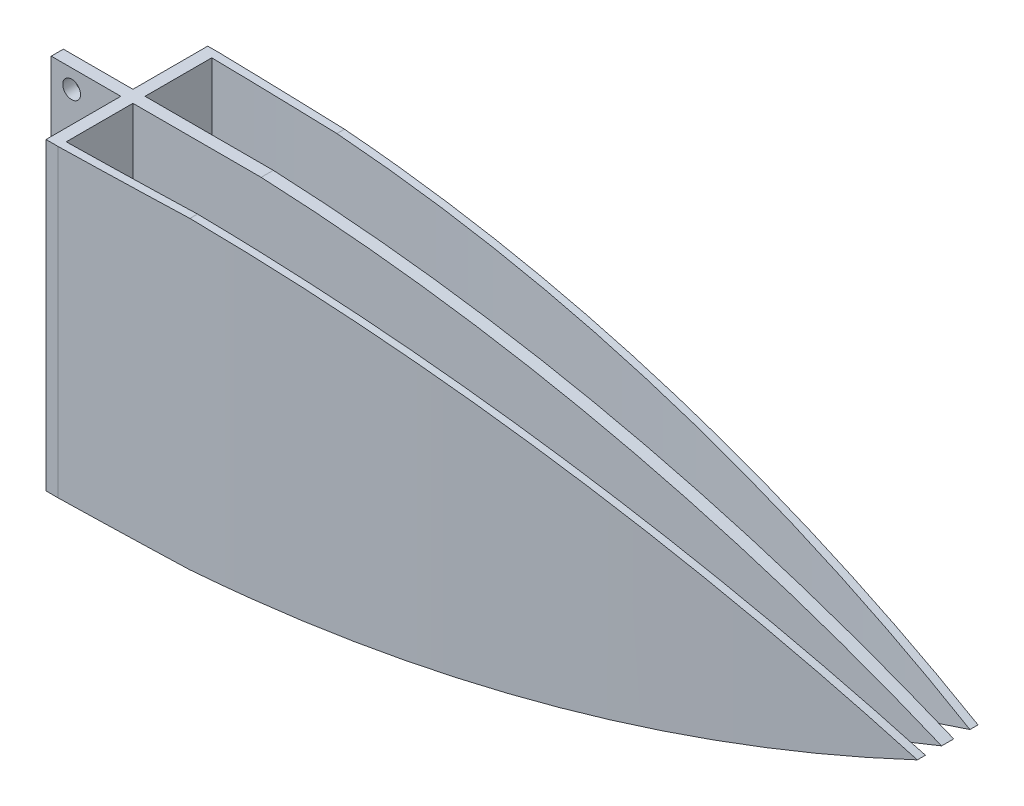
from build123d import *

# Parameters (mm, degrees)
EXTRUDE_1_DEPTH          = 0.75
EXTRUDE_1_DEPTH_BACK     = 0.75
SKETCH_1_W               = 10
SKETCH_1_H               = 38
SKETCH_1_R               = 1.1
SKETCH_3_W               = 20
SKETCH_3_H               = 38.036879249
EXTRUDE_2_DEPTH          = 1.5
EXTRUDE_3_DEPTH          = 0.75
EXTRUDE_3_DEPTH_BACK     = 0.75
EXTRUDE_4_DEPTH          = 38
CUT_EXTRUDE_1_DEPTH      = 10
CUT_EXTRUDE_1_DEPTH_BACK = 20
CUT_EXTRUDE_4_DEPTH      = 0.2
CUT_EXTRUDE_4_DEPTH_BACK = 0.2
SKETCH_10_W              = 112.497058814
SKETCH_10_H              = 20.543414641
CUT_EXTRUDE_5_DEPTH      = 0.2
CUT_EXTRUDE_5_DEPTH_BACK = 0.2
SKETCH_11_W              = 104.514605189
SKETCH_11_H              = 21.657747512


with BuildPart() as part:
    # 草圖1 → 填料-伸長1 (new, two sides: drawn at the far end of the back side and taken through both)
    with BuildSketch(Plane.XY.offset(-EXTRUDE_1_DEPTH_BACK)):
        with Locations((-4.101832994, 0.735234216)):
            Rectangle(SKETCH_1_W, SKETCH_1_H)
        with Locations((-6.601832994, -15.764765784)):
            Circle(SKETCH_1_R, mode=Mode.SUBTRACT)
        with Locations((-6.578411405, 17.235234216)):
            Circle(SKETCH_1_R, mode=Mode.SUBTRACT)
    extrude(amount=EXTRUDE_1_DEPTH + EXTRUDE_1_DEPTH_BACK)

    # 草圖3 → 填料-伸長2 (add)
    with BuildSketch(Plane(origin=(-0.5, 0, 0), x_dir=(0, 0, -1), z_dir=(1, 0, 0))):
        with Locations((0, 0.716794592)):
            Rectangle(SKETCH_3_W, SKETCH_3_H)
    extrude(amount=EXTRUDE_2_DEPTH)

    # 草圖4 → 填料-伸長3 (add, two sides: drawn at the far end of the back side and taken through both)
    with BuildSketch(Plane.XY.offset(-EXTRUDE_3_DEPTH_BACK)):
        with BuildLine():
            Line((1, 19.735234216), (1, -18.298860138))
            ThreePointArc((1, -18.298860138), (51.989546932, -13.993809638), (101, 0.718187039))
            ThreePointArc((101, 0.718187039), (51.989546932, 15.430183716), (1, 19.735234216))
        make_face()
    extrude(amount=EXTRUDE_3_DEPTH + EXTRUDE_3_DEPTH_BACK)

    # 草圖5 → 填料-伸長4 (add)
    with BuildSketch(Plane(origin=(0, 19.735234216, 0), x_dir=(1, 0, 0), z_dir=(0, 1, 0))):
        with BuildLine():
            Line((1, -9), (1, -10))
            ThreePointArc((1, -10), (51.064071237, -7.900139791), (101, -3.75))
            Line((101, -3.75), (101, -2.75))
            ThreePointArc((101, -2.75), (51.071468752, -7.018500027), (1, -9))
        make_face()
        with BuildLine():
            Line((101, 2.75), (101, 3.75))
            ThreePointArc((101, 3.75), (51.064071237, 7.900139791), (1, 10))
            Line((1, 10), (1, 9))
            ThreePointArc((1, 9), (51.071468752, 7.018500027), (101, 2.75))
        make_face()
    extrude(amount=-EXTRUDE_4_DEPTH)

    # 草圖8 → 除料-伸長1 (cut, two sides: drawn at the far end of the back side and taken through both)
    with BuildSketch(Plane.XY.offset(10).offset(-CUT_EXTRUDE_1_DEPTH_BACK)):
        with BuildLine():
            Line((13.103688801, -18.23809131), (101, -18.264765784))
            Line((101, -18.264765784), (101, 0.718187039))
            ThreePointArc((101, 0.718187039), (57.921072507, -12.790381672), (13.103688801, -18.23809131))
        make_face()
        with BuildLine():
            ThreePointArc((13.103688801, 19.674465387), (57.921072507, 14.22675575), (101, 0.718187039))
            Line((101, 0.718187039), (101, 19.701139862))
            Line((101, 19.701139862), (13.103688801, 19.674465387))
        make_face()
    extrude(amount=CUT_EXTRUDE_1_DEPTH + CUT_EXTRUDE_1_DEPTH_BACK, mode=Mode.SUBTRACT)

    # 草圖10 → 除料-伸長4 (cut, two sides: drawn at the far end of the back side and taken through both)
    with BuildSketch(Plane(origin=(0, 19.735234216, 0), x_dir=(1, 0, 0), z_dir=(0, 1, 0)).offset(-CUT_EXTRUDE_4_DEPTH_BACK)):
        with Locations((46.49437126, 0.271707321)):
            Rectangle(SKETCH_10_W, SKETCH_10_H)
    extrude(amount=CUT_EXTRUDE_4_DEPTH + CUT_EXTRUDE_4_DEPTH_BACK, mode=Mode.SUBTRACT)

    # 草圖11 → 除料-伸長5 (cut, two sides: drawn at the far end of the back side and taken through both)
    with BuildSketch(Plane(origin=(0, -18.301645033, 0), x_dir=(-1, 0, 0), z_dir=(0, -1, 0)).offset(-CUT_EXTRUDE_5_DEPTH_BACK)):
        with Locations((-51.541283716, 0.828873756)):
            Rectangle(SKETCH_11_W, SKETCH_11_H)
    extrude(amount=CUT_EXTRUDE_5_DEPTH + CUT_EXTRUDE_5_DEPTH_BACK, mode=Mode.SUBTRACT)


solid = part.part
